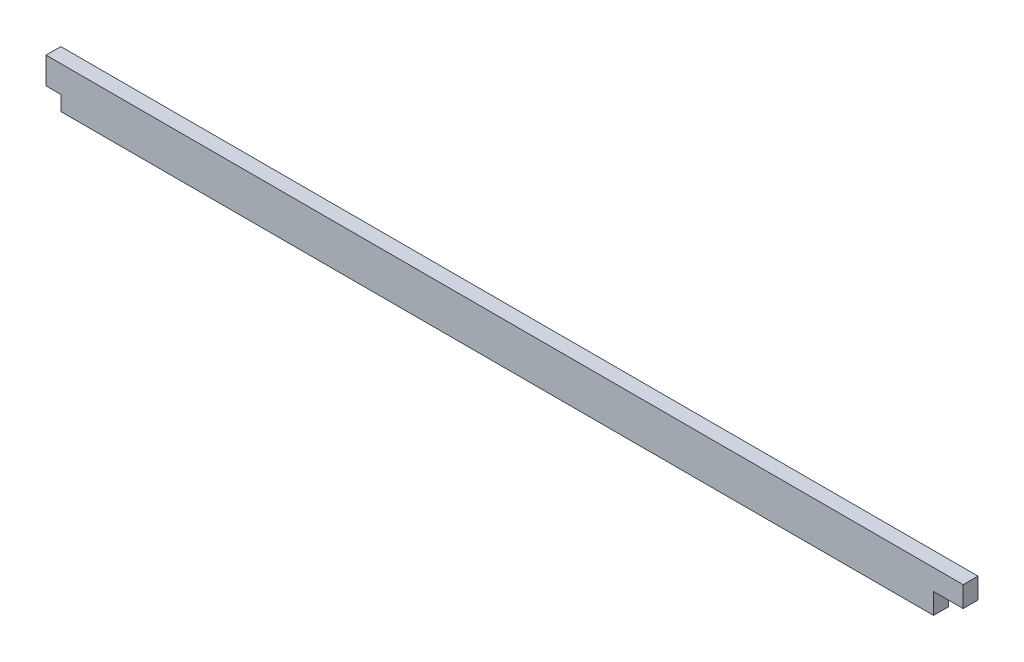
from build123d import *

# Parameters (mm, degrees)
EXTRUDE_1_DEPTH = 1.4


with BuildPart() as part:
    # Эскиз1 → Бобышка-Вытянуть1 (new, symmetric)
    with BuildSketch(Plane.XY):
        Polygon((86.710588683, 0), (81.110588683, 0), (81.110588683, -3.92), (-83.910588683, -3.92), (-83.910588683, -1.12), (-86.710588683, -1.12), (-86.710588683, 3.92), (-43.02487952, 3.92), (86.710588683, 3.92), align=None)
    extrude(amount=EXTRUDE_1_DEPTH, both=True)


solid = part.part
